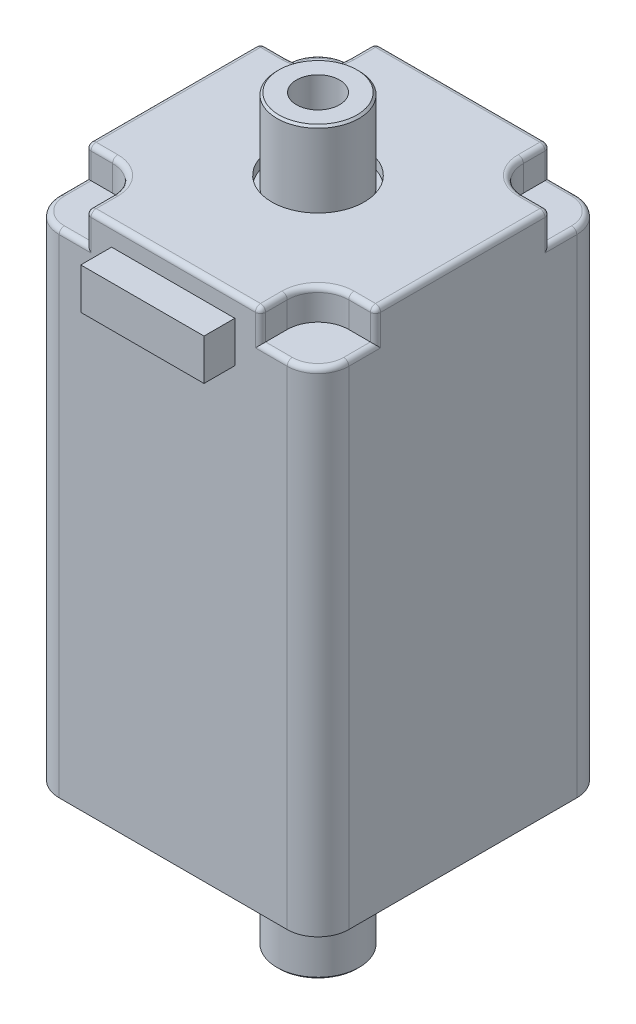
from build123d import *

# Parameters (mm, degrees)
SKETCH1_W               = 28.2
SKETCH1_H               = 28.2
BOSS_EXTRUDE1_DEPTH     = 51
SKETCH2_R               = 11
BOSS_EXTRUDE2_DEPTH     = 2
M2_5_TAPPED_HOLE1_D     = 2.05
M2_5_TAPPED_HOLE1_DEPTH = 15
M2_5_TAPPED_HOLE1_TIP   = 0.615882135
FILLET1_R               = 3
SKETCH6_R               = 4
BOSS_EXTRUDE3_DEPTH     = 14
SKETCH7_R               = 4
BOSS_EXTRUDE4_DEPTH     = 7
M5_TAPPED_HOLE1_D       = 4.2
CHAMFER1_SIZE           = 0.2
SKETCH10_R              = 4.5
SKETCH10_R_2            = 4
CUT_EXTRUDE1_DEPTH      = 1
SKETCH11_W              = 12
SKETCH11_H              = 4
BOSS_EXTRUDE5_DEPTH     = 3
CUT_EXTRUDE2_DEPTH      = 3
CIRPATTERN1_COUNT       = 4
FILLET2_R               = 0.5


with BuildPart() as part:
    # Sketch1 → Boss-Extrude1 (new body)
    with BuildSketch(Plane(origin=(0, 0, 0), x_dir=(1, 0, 0), z_dir=(0, 1, 0))):
        Rectangle(SKETCH1_W, SKETCH1_H)
    extrude(amount=BOSS_EXTRUDE1_DEPTH)

    # Sketch2 → Boss-Extrude2 (add)
    with BuildSketch(Plane.XZ):
        Circle(SKETCH2_R)
    extrude(amount=BOSS_EXTRUDE2_DEPTH)

    # M2.5 Tapped Hole1
    with Locations(Plane(origin=(0, 0, 0), x_dir=(-1, 0, 0), z_dir=(0, -1, 0))):
        with Locations((11.5, -11.5), (-11.5, -11.5), (-11.5, 11.5), (11.5, 11.5)):
            Hole(M2_5_TAPPED_HOLE1_D / 2, depth=M2_5_TAPPED_HOLE1_DEPTH)
            with Locations((0, 0, -(M2_5_TAPPED_HOLE1_DEPTH + M2_5_TAPPED_HOLE1_TIP / 2))):  # 118° drill point
                Cone(0, M2_5_TAPPED_HOLE1_D / 2, M2_5_TAPPED_HOLE1_TIP, mode=Mode.SUBTRACT)

    # Fillet1
    fillet1_edges = [part.edges().sort_by_distance(p)[0] for p in [
        (14.1, 25.5, 14.1),
        (-14.1, 25.5, 14.1),
        (-14.1, 25.5, -14.1),
        (14.1, 25.5, -14.1),
    ]]
    fillet(fillet1_edges, radius=FILLET1_R)

    # Sketch6 → Boss-Extrude3 (add)
    with BuildSketch(Plane.XZ):
        Circle(SKETCH6_R)
    extrude(amount=BOSS_EXTRUDE3_DEPTH)

    # Sketch7 → Boss-Extrude4 (add)
    with BuildSketch(Plane(origin=(0, 51, 0), x_dir=(1, 0, 0), z_dir=(0, 1, 0))):
        Circle(SKETCH7_R)
    extrude(amount=BOSS_EXTRUDE4_DEPTH)

    # M5 Tapped Hole1 (through all)
    with Locations(Plane(origin=(0, 58, 0), x_dir=(1, 0, 0), z_dir=(0, 1, 0))):
        with Locations((0, 0)):
            Hole(M5_TAPPED_HOLE1_D / 2)

    # Chamfer1
    chamfer1_edges = [part.edges().sort_by_distance(p)[0] for p in [
        (-11, -2, 0),
        (-4, -14, 0),
        (-4, 58, 0),
    ]]
    chamfer(chamfer1_edges, length=CHAMFER1_SIZE)

    # Sketch10 → Cut-Extrude1 (cut)
    with BuildSketch(Plane(origin=(0, 51, 0), x_dir=(1, 0, 0), z_dir=(0, 1, 0))):
        Circle(SKETCH10_R)
        Circle(SKETCH10_R_2, mode=Mode.SUBTRACT)
    extrude(amount=-CUT_EXTRUDE1_DEPTH, mode=Mode.SUBTRACT)

    # Sketch11 → Boss-Extrude5 (add)
    with BuildSketch(Plane.XY.offset(14.1)):
        with Locations((0, 47)):
            Rectangle(SKETCH11_W, SKETCH11_H)
    extrude(amount=BOSS_EXTRUDE5_DEPTH)

    # Sketch12 → Cut-Extrude2 (cut)
    with BuildSketch(Plane(origin=(0, 51, 0), x_dir=(1, 0, 0), z_dir=(0, 1, 0))):
        with BuildLine():
            ThreePointArc((-11.5, 8.5), (-9.378679656, 9.378679656), (-8.5, 11.5))
            Line((-8.5, 11.5), (-8.5, 14.1))
            Line((-8.5, 14.1), (-11.1, 14.1))
            ThreePointArc((-11.1, 14.1), (-13.221320344, 13.221320344), (-14.1, 11.1))
            Line((-14.1, 11.1), (-14.1, 8.5))
            Line((-14.1, 8.5), (-11.5, 8.5))
        make_face()
    cut_extrude2 = extrude(amount=-CUT_EXTRUDE2_DEPTH, mode=Mode.SUBTRACT)

    # CirPattern1: Cut-Extrude2 ×4 about axis
    cirpattern1_axis = Axis((0, 0, 0), (0, 1, 0))
    for i in range(1, CIRPATTERN1_COUNT):
        add(cut_extrude2.rotate(cirpattern1_axis, i * 360 / CIRPATTERN1_COUNT), mode=Mode.SUBTRACT)

    # Fillet2
    fillet2_edges = [part.edges().sort_by_distance(p)[0] for p in [
        (-14.1, 51, 0),
        (-9.378679656, 51, -9.378679656),
        (-12.8, 51, -8.5),
        (-14.1, 48, -9.8),
        (-14.1, 49.5, -8.5),
        (-13.221320344, 48, -13.221320344),
        (-9.8, 48, -14.1),
        (-8.5, 49.5, -14.1),
        (-8.5, 51, -12.8),
        (0, 51, -14.1),
        (9.378679656, 51, -9.378679656),
        (8.5, 51, -12.8),
        (9.8, 48, -14.1),
        (8.5, 49.5, -14.1),
        (13.221320344, 48, -13.221320344),
        (14.1, 48, -9.8),
        (14.1, 49.5, -8.5),
        (12.8, 51, -8.5),
        (14.1, 51, 0),
        (9.378679656, 51, 9.378679656),
        (12.8, 51, 8.5),
        (14.1, 48, 9.8),
        (14.1, 49.5, 8.5),
        (13.221320344, 48, 13.221320344),
        (9.8, 48, 14.1),
        (8.5, 49.5, 14.1),
        (8.5, 51, 12.8),
        (0, 51, 14.1),
        (-9.378679656, 51, 9.378679656),
        (-8.5, 51, 12.8),
        (-9.8, 48, 14.1),
        (-8.5, 49.5, 14.1),
        (-13.221320344, 48, 13.221320344),
        (-14.1, 48, 9.8),
        (-14.1, 49.5, 8.5),
        (-12.8, 51, 8.5),
    ]]
    fillet(fillet2_edges, radius=FILLET2_R)


solid = part.part
